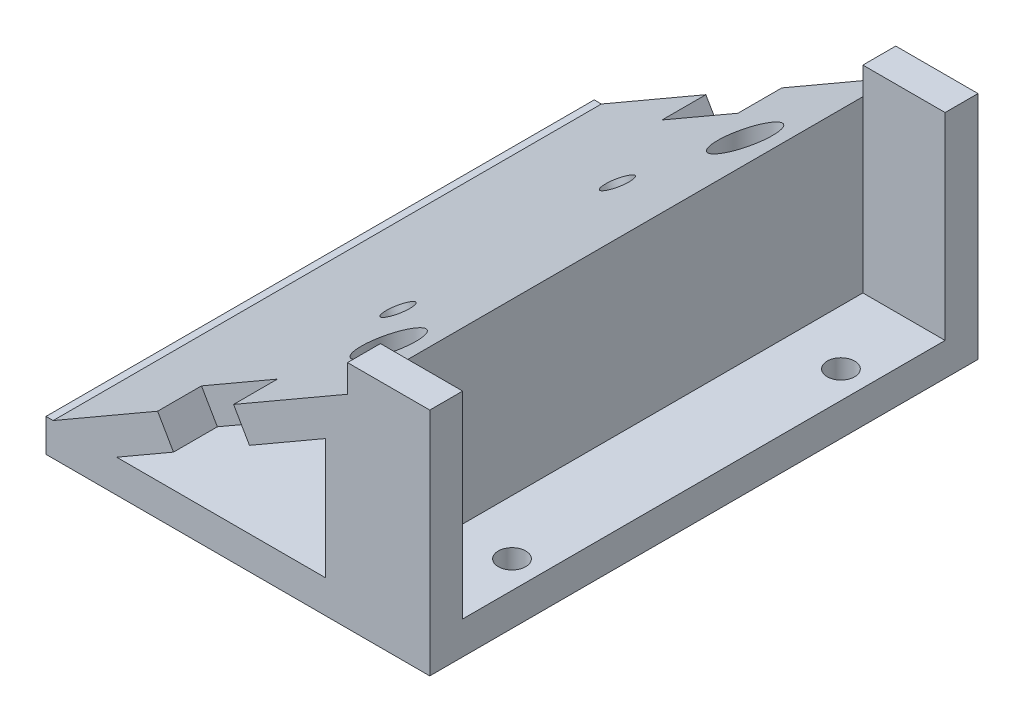
from build123d import *

# Parameters (mm, degrees)
SKETCH1_W                      = 35
SKETCH1_H                      = 50
BOSS_EXTRUDE1_DEPTH            = 3
SKETCH2_R                      = 1.5
SKETCH2_R_2                    = 1.25
CUT_EXTRUDE1_DEPTH             = 4
BOSS_EXTRUDE2_DEPTH            = 50
CUT_EXTRUDE5_DEPTH             = 51
SKETCH8_R                      = 2.5
CUT_EXTRUDE6_DEPTH             = 16.5
CUT_EXTRUDE6_DEPTH_BACK        = 1
CUT_EXTRUDE7_REACH             = 21.771
SKETCH9_R                      = 1.25
SKETCH10_R                     = 2.5
CUT_EXTRUDE8_DEPTH             = 0.5
CUT_EXTRUDE8_DIRECTION_2_REACH = 18.874
SKETCH11_W                     = 7.5
SKETCH11_H                     = 3
BOSS_EXTRUDE3_DEPTH            = 18
CUT_EXTRUDE9_REACH             = 21.771
SKETCH14_W                     = 8
SKETCH14_H                     = 4


with BuildPart() as part:
    # Sketch1 → Boss-Extrude1 (new body)
    with BuildSketch(Plane(origin=(0, 0, 0), x_dir=(1, 0, 0), z_dir=(0, 1, 0))):
        with Locations((-87.623418825, 48.010907537)):
            Rectangle(SKETCH1_W, SKETCH1_H)
    extrude(amount=BOSS_EXTRUDE1_DEPTH)

    # Sketch2 → Cut-Extrude1 (cut, through all)
    with BuildSketch(Plane(origin=(0, 3, 0), x_dir=(1, 0, 0), z_dir=(0, 1, 0))):
        with Locations((-82.623418825, 64.263988227)):
            Circle(SKETCH2_R)
        with Locations((-82.623418825, 31.763988227)):
            Circle(SKETCH2_R)
        with Locations((-72.623418825, 33.010907537)):
            Circle(SKETCH2_R_2)
        with Locations((-72.623418825, 63.010907537)):
            Circle(SKETCH2_R_2)
    extrude(amount=-CUT_EXTRUDE1_DEPTH, mode=Mode.SUBTRACT)

    # Sketch4 → Boss-Extrude2 (add)
    with BuildSketch(Plane.XY.offset(-23.010907537)):
        Polygon((-77.623418825, 3), (-104.470206342, 3), (-77.623418825, 18.5), align=None)
    extrude(amount=-BOSS_EXTRUDE2_DEPTH)

    # Sketch6 → Cut-Extrude5 (cut, through all)
    with BuildSketch(Plane.XY.offset(-23.010907537)):
        Polygon((-98.675977708, 3), (-79.623418825, 3), (-79.623418825, 14), align=None)
    extrude(amount=-CUT_EXTRUDE5_DEPTH, mode=Mode.SUBTRACT)

    # Sketch8 → Cut-Extrude6 (cut, two sides)
    with BuildSketch(Plane(origin=(0, 3, 0), x_dir=(1, 0, 0), z_dir=(0, 1, 0))) as cut_extrude6_sk:
        with Locations((-82.623418825, 31.763988227)):
            Circle(SKETCH8_R)
        with Locations((-82.623418825, 64.263988227)):
            Circle(SKETCH8_R)
    extrude(amount=CUT_EXTRUDE6_DEPTH, mode=Mode.SUBTRACT)
    extrude(cut_extrude6_sk.sketch, amount=-CUT_EXTRUDE6_DEPTH_BACK, mode=Mode.SUBTRACT)

    # Sketch9 → Cut-Extrude7 (cut, up to next)
    with BuildSketch(Plane(origin=(-27.416589691, 47.486926315, 0), x_dir=(0.866025404, 0.5, 0), z_dir=(-0.5, 0.866025404, 0)), mode=Mode.PRIVATE) as cut_extrude7_sk1:
        with Locations((-69.973852631, 58.010907537)):
            Circle(SKETCH9_R)
    cut_extrude7_tool1 = extrude(cut_extrude7_sk1.sketch, amount=-CUT_EXTRUDE7_REACH, mode=Mode.PRIVATE) & part.part
    add(cut_extrude7_tool1.solids().sort_by_distance((-88.015724, 12.5, -58.010908))[0], mode=Mode.SUBTRACT)
    # Sketch9 → Cut-Extrude7 (cut, up to next)
    with BuildSketch(Plane(origin=(-27.416589691, 47.486926315, 0), x_dir=(0.866025404, 0.5, 0), z_dir=(-0.5, 0.866025404, 0)), mode=Mode.PRIVATE) as cut_extrude7_sk2:
        with Locations((-69.973852631, 38.010907537)):
            Circle(SKETCH9_R)
    cut_extrude7_tool2 = extrude(cut_extrude7_sk2.sketch, amount=-CUT_EXTRUDE7_REACH, mode=Mode.PRIVATE) & part.part
    add(cut_extrude7_tool2.solids().sort_by_distance((-88.015724, 12.5, -38.010908))[0], mode=Mode.SUBTRACT)

    # Sketch10 → Cut-Extrude8 (cut)
    with BuildSketch(Plane(origin=(-25.968032533, 44.977951719, 0), x_dir=(-0.866025404, -0.5, 0), z_dir=(0.5, -0.866025404, 0))):
        with Locations((69.973852631, 58.010907537)):
            Circle(SKETCH10_R)
        with Locations((69.973852631, 38.010907537)):
            Circle(SKETCH10_R)
    extrude(amount=-CUT_EXTRUDE8_DEPTH, mode=Mode.SUBTRACT)

    # Sketch10 → Cut-Extrude8 direction 2 (cut, up to next)
    with BuildSketch(Plane(origin=(-25.968032533, 44.977951719, 0), x_dir=(-0.866025404, -0.5, 0), z_dir=(0.5, -0.866025404, 0)), mode=Mode.PRIVATE) as cut_extrude8_direction_2_sk1:
        with Locations((69.973852631, 58.010907537)):
            Circle(SKETCH10_R)
    cut_extrude8_direction_2_tool1 = extrude(cut_extrude8_direction_2_sk1.sketch, amount=CUT_EXTRUDE8_DIRECTION_2_REACH, mode=Mode.PRIVATE) & part.part
    add(cut_extrude8_direction_2_tool1.solids().sort_by_distance((-86.567167, 9.991025, -58.010908))[0], mode=Mode.SUBTRACT)
    # Sketch10 → Cut-Extrude8 direction 2 (cut, up to next)
    with BuildSketch(Plane(origin=(-25.968032533, 44.977951719, 0), x_dir=(-0.866025404, -0.5, 0), z_dir=(0.5, -0.866025404, 0)), mode=Mode.PRIVATE) as cut_extrude8_direction_2_sk2:
        with Locations((69.973852631, 38.010907537)):
            Circle(SKETCH10_R)
    cut_extrude8_direction_2_tool2 = extrude(cut_extrude8_direction_2_sk2.sketch, amount=CUT_EXTRUDE8_DIRECTION_2_REACH, mode=Mode.PRIVATE) & part.part
    add(cut_extrude8_direction_2_tool2.solids().sort_by_distance((-86.567167, 9.991025, -38.010908))[0], mode=Mode.SUBTRACT)

    # Sketch11 → Boss-Extrude3 (add)
    with BuildSketch(Plane(origin=(0, 3, 0), x_dir=(1, 0, 0), z_dir=(0, 1, 0))):
        with Locations((-73.873418825, 24.510907537)):
            Rectangle(SKETCH11_W, SKETCH11_H)
        with Locations((-73.873418825, 71.510907537)):
            Rectangle(SKETCH11_W, SKETCH11_H)
    extrude(amount=BOSS_EXTRUDE3_DEPTH)

    # Sketch14 → Cut-Extrude9 (cut, up to next)
    with BuildSketch(Plane(origin=(-27.416589691, 47.486926315, 0), x_dir=(0.866025404, 0.5, 0), z_dir=(-0.5, 0.866025404, 0)), mode=Mode.PRIVATE) as cut_extrude9_sk1:
        with Locations((-73.973852631, 25.010907537)):
            Rectangle(SKETCH14_W, SKETCH14_H)
    cut_extrude9_tool1 = extrude(cut_extrude9_sk1.sketch, amount=-CUT_EXTRUDE9_REACH, mode=Mode.PRIVATE) & part.part
    add(cut_extrude9_tool1.solids().sort_by_distance((-91.479825, 10.5, -25.010908))[0], mode=Mode.SUBTRACT)
    # Sketch14 → Cut-Extrude9 (cut, up to next)
    with BuildSketch(Plane(origin=(-27.416589691, 47.486926315, 0), x_dir=(0.866025404, 0.5, 0), z_dir=(-0.5, 0.866025404, 0)), mode=Mode.PRIVATE) as cut_extrude9_sk2:
        with Locations((-73.973852631, 71.010907537)):
            Rectangle(SKETCH14_W, SKETCH14_H)
    cut_extrude9_tool2 = extrude(cut_extrude9_sk2.sketch, amount=-CUT_EXTRUDE9_REACH, mode=Mode.PRIVATE) & part.part
    add(cut_extrude9_tool2.solids().sort_by_distance((-91.479825, 10.5, -71.010908))[0], mode=Mode.SUBTRACT)


solid = part.part
